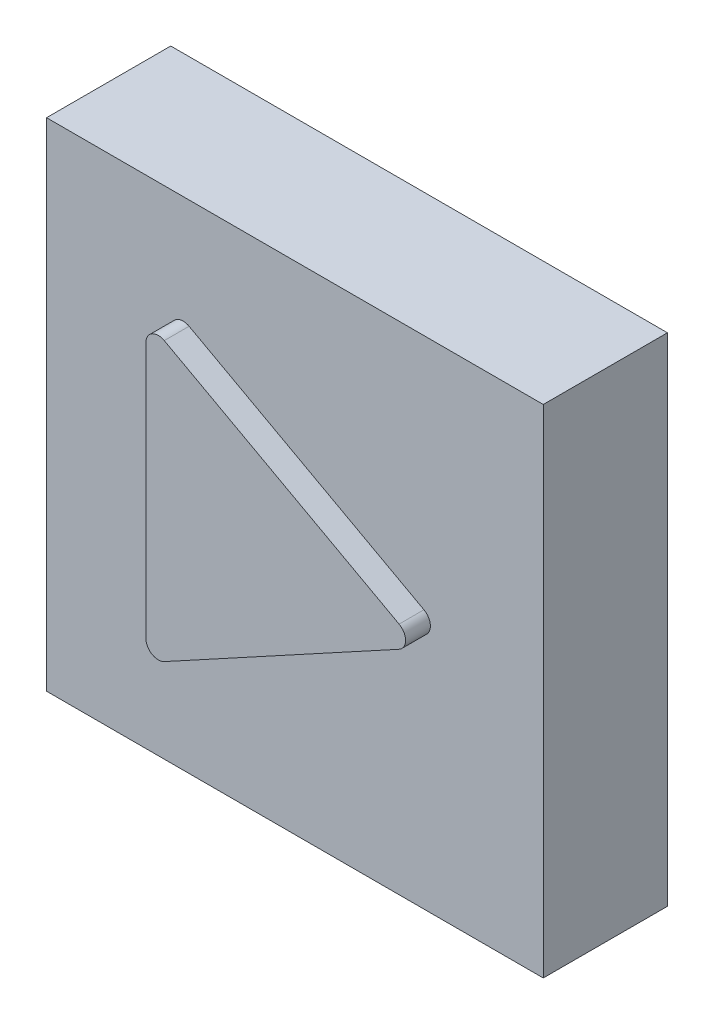
from build123d import *

# Parameters (mm, degrees)
SKETCH1_W           = 20
SKETCH1_H           = 20
BOSS_EXTRUDE1_DEPTH = 5
SKETCH6_R           = 0.6
CUT_EXTRUDE1_DEPTH  = 5
BOSS_EXTRUDE2_DEPTH = 1


with BuildPart() as part:
    # Sketch1 → Boss-Extrude1 (new body)
    with BuildSketch(Plane.XY):
        Rectangle(SKETCH1_W, SKETCH1_H)
    extrude(amount=BOSS_EXTRUDE1_DEPTH)

    # Sketch6 → Cut-Extrude1 (cut)
    with BuildSketch(Plane.XY.offset(5)):
        Circle(SKETCH6_R)
    extrude(amount=-CUT_EXTRUDE1_DEPTH, mode=Mode.SUBTRACT)

    # Sketch2 → Boss-Extrude2 (add)
    with BuildSketch(Plane.XY.offset(5)):
        with BuildLine():
            Line((-5, 5.157728905), (-5, -5.157728905))
            ThreePointArc((-5, -5.157728905), (-4.755232215, -5.58767834), (-4.260573935, -5.596676692))
            Line((-4.260573935, -5.596676692), (5.195262391, -0.438947786))
            ThreePointArc((5.195262391, -0.438947786), (5.455836326, 0), (5.195262391, 0.438947786))
            Line((5.195262391, 0.438947786), (-4.260573935, 5.596676692))
            ThreePointArc((-4.260573935, 5.596676692), (-4.755232215, 5.58767834), (-5, 5.157728905))
        make_face()
    extrude(amount=BOSS_EXTRUDE2_DEPTH)


solid = part.part
